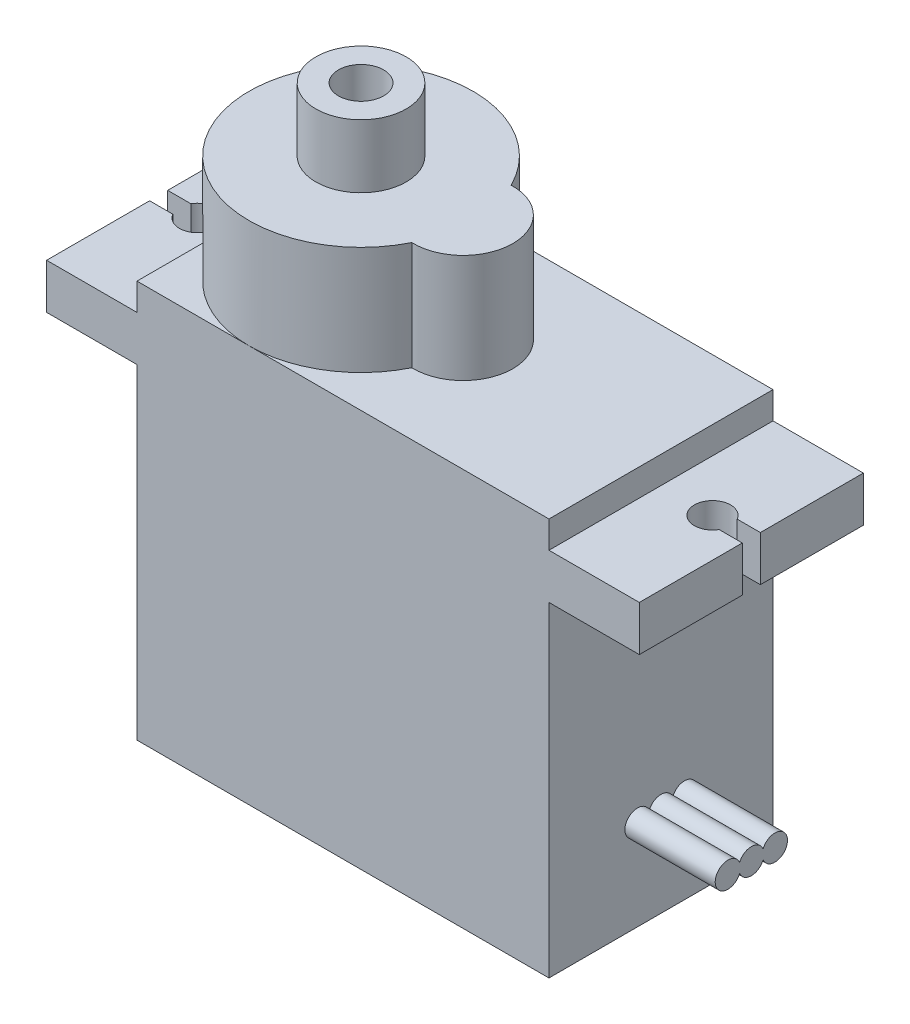
from build123d import *

# Parameters (mm, degrees)
SKETCH1_W           = 22.8
SKETCH1_H           = 12.4
BOSS_EXTRUDE1_DEPTH = 22
BOSS_EXTRUDE3_DEPTH = 6
SKETCH3_R           = 2.5
SKETCH3_R_2         = 1.25
BOSS_EXTRUDE4_DEPTH = 3.5
BOSS_EXTRUDE5_DEPTH = 2.5
CUT_EXTRUDE1_DEPTH  = 1
BOSS_EXTRUDE6_DEPTH = 5


with BuildPart() as part:
    # Sketch1 → Boss-Extrude1 (new body)
    with BuildSketch(Plane(origin=(0, 0, 0), x_dir=(1, 0, 0), z_dir=(0, 1, 0))):
        Rectangle(SKETCH1_W, SKETCH1_H)
    extrude(amount=BOSS_EXTRUDE1_DEPTH)

    # Sketch2 → Boss-Extrude3 (add)
    with BuildSketch(Plane(origin=(0, 22, 0), x_dir=(1, 0, 0), z_dir=(0, 1, 0))):
        with BuildLine():
            ThreePointArc((0.357522124, 2.748444622), (-11.4, 0), (0.357522124, -2.748444622))
            ThreePointArc((0.357522124, -2.748444622), (3.2, 0), (0.357522124, 2.748444622))
        make_face()
    extrude(amount=BOSS_EXTRUDE3_DEPTH)

    # Sketch3 → Boss-Extrude4 (add)
    with BuildSketch(Plane(origin=(0, 28, 0), x_dir=(1, 0, 0), z_dir=(0, 1, 0))):
        with Locations((-5.2, 0)):
            Circle(SKETCH3_R)
        with Locations((-5.2, 0)):
            Circle(SKETCH3_R_2, mode=Mode.SUBTRACT)
    extrude(amount=BOSS_EXTRUDE4_DEPTH)

    # Sketch4 → Boss-Extrude5 (add)
    with BuildSketch(Plane(origin=(0, 18, 0), x_dir=(1, 0, 0), z_dir=(0, 1, 0))):
        with BuildLine():
            Line((-16.4, -0.5), (-16.4, -6.2))
            Line((-16.4, -6.2), (-11.4, -6.2))
            Line((-11.4, -6.2), (-11.4, 6.2))
            Line((-11.4, 6.2), (-16.4, 6.2))
            Line((-16.4, 6.2), (-16.4, 0.5))
            Line((-16.4, 0.5), (-15.116025404, 0.5))
            ThreePointArc((-15.116025404, 0.5), (-13.25, 0), (-15.116025404, -0.5))
            Line((-15.116025404, -0.5), (-16.4, -0.5))
        make_face()
    boss_extrude5 = extrude(amount=BOSS_EXTRUDE5_DEPTH)

    # Sketch5 → Cut-Extrude1 (cut)
    with BuildSketch(Plane.XZ.offset(-18)):
        with BuildLine():
            Line((-11.4, -5.2), (-11.4, 5.2))
            Line((-11.4, 5.2), (-15.4, 5.2))
            Line((-15.4, 5.2), (-15.4, 1.636306817))
            ThreePointArc((-15.4, 1.636306817), (-12.25, 0), (-15.4, -1.636306817))
            Line((-15.4, -1.636306817), (-15.4, -5.2))
            Line((-15.4, -5.2), (-11.4, -5.2))
        make_face()
    cut_extrude1 = extrude(amount=-CUT_EXTRUDE1_DEPTH, mode=Mode.SUBTRACT)

    # Mirror1: Boss-Extrude5, Cut-Extrude1 across plane
    add(boss_extrude5.mirror(Plane(origin=(0, 0, 0), x_dir=(0, 0, 1), z_dir=(1, 0, 0))))
    add(cut_extrude1.mirror(Plane(origin=(0, 0, 0), x_dir=(0, 0, 1), z_dir=(1, 0, 0))), mode=Mode.SUBTRACT)

    # Sketch6 → Boss-Extrude6 (add)
    with BuildSketch(Plane(origin=(11.4, 0, 0), x_dir=(0, 0, -1), z_dir=(1, 0, 0))):
        with BuildLine():
            ThreePointArc((-0.65, 4.740192379), (0, 4.3), (0.65, 4.740192379))
            ThreePointArc((0.65, 4.740192379), (2, 5), (0.65, 5.259807621))
            ThreePointArc((0.65, 5.259807621), (0, 5.7), (-0.65, 5.259807621))
            ThreePointArc((-0.65, 5.259807621), (-2, 5), (-0.65, 4.740192379))
        make_face()
    extrude(amount=BOSS_EXTRUDE6_DEPTH)


solid = part.part
